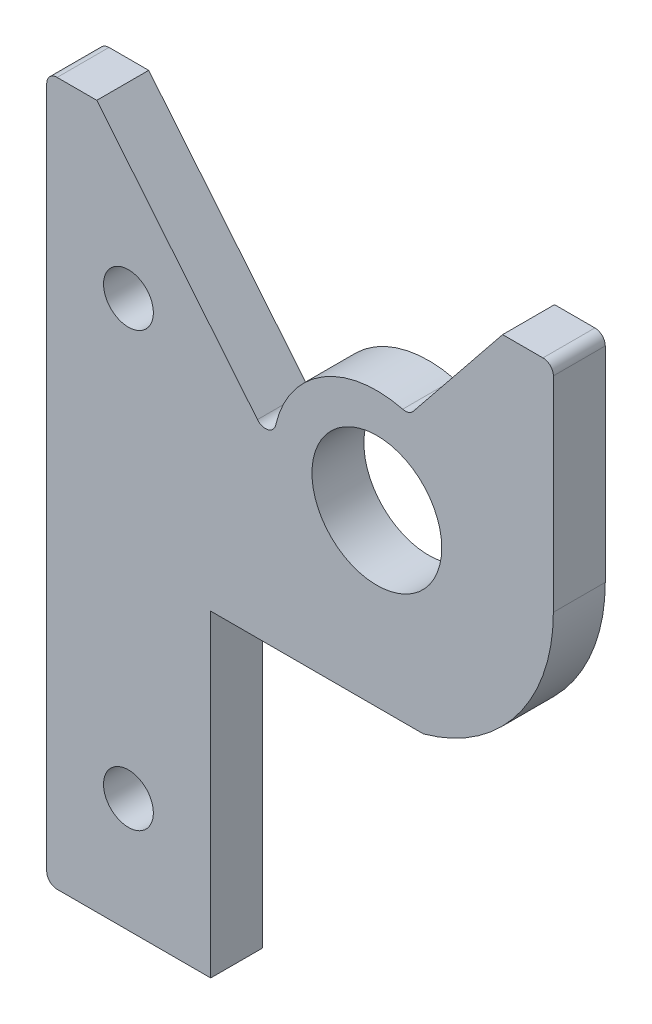
from build123d import *

# Parameters (mm, degrees)
SKETCH1_R           = 3.048
SKETCH1_R_2         = 7.9375
BOSS_EXTRUDE1_DEPTH = 6.35


with BuildPart() as part:
    # Sketch1 → Boss-Extrude1 (new body)
    with BuildSketch(Plane.XY):
        with BuildLine():
            Line((21.59, 0), (21.59, 25.042396902))
            ThreePointArc((21.59, 25.042396902), (21.218025612, 25.940422514), (20.32, 26.312396902))
            Line((20.32, 26.312396902), (15.384027181, 26.312396902))
            Line((15.384027181, 26.312396902), (4.464894623, 12.734941429))
            ThreePointArc((4.464894623, 12.734941429), (3.875986132, 12.325731507), (3.159297438, 12.300765818))
            ThreePointArc((3.159297438, 12.300765818), (-6.605300924, 10.84711942), (-12.378605801, 2.839034768))
            ThreePointArc((-12.378605801, 2.839034768), (-13.326403154, 1.886506555), (-14.59892418, 2.318154625))
            Line((-14.59892418, 2.318154625), (-34.253888671, 26.312396902))
            Line((-34.253888671, 26.312396902), (-39.107436935, 26.312396902))
            ThreePointArc((-39.107436935, 26.312396902), (-40.005462547, 25.940422514), (-40.377436935, 25.042396902))
            Line((-40.377436935, 25.042396902), (-40.377436935, -58.42))
            ThreePointArc((-40.377436935, -58.42), (-40.005462547, -59.318025612), (-39.107436935, -59.69))
            Line((-39.107436935, -59.69), (-20.319056935, -59.69))
            Line((-20.319056935, -59.69), (-20.319056935, -20.828))
            Line((-20.319056935, -20.828), (5.685289439, -20.828))
            ThreePointArc((5.685289439, -20.828), (17.159159347, -13.103104613), (21.59, 0))
        make_face()
        with Locations((-30.382536935, 7.262396902)):
            Circle(SKETCH1_R, mode=Mode.SUBTRACT)
        Circle(SKETCH1_R_2, mode=Mode.SUBTRACT)
        with Locations((-30.382536935, -45.72)):
            Circle(SKETCH1_R, mode=Mode.SUBTRACT)
    extrude(amount=BOSS_EXTRUDE1_DEPTH)


solid = part.part
